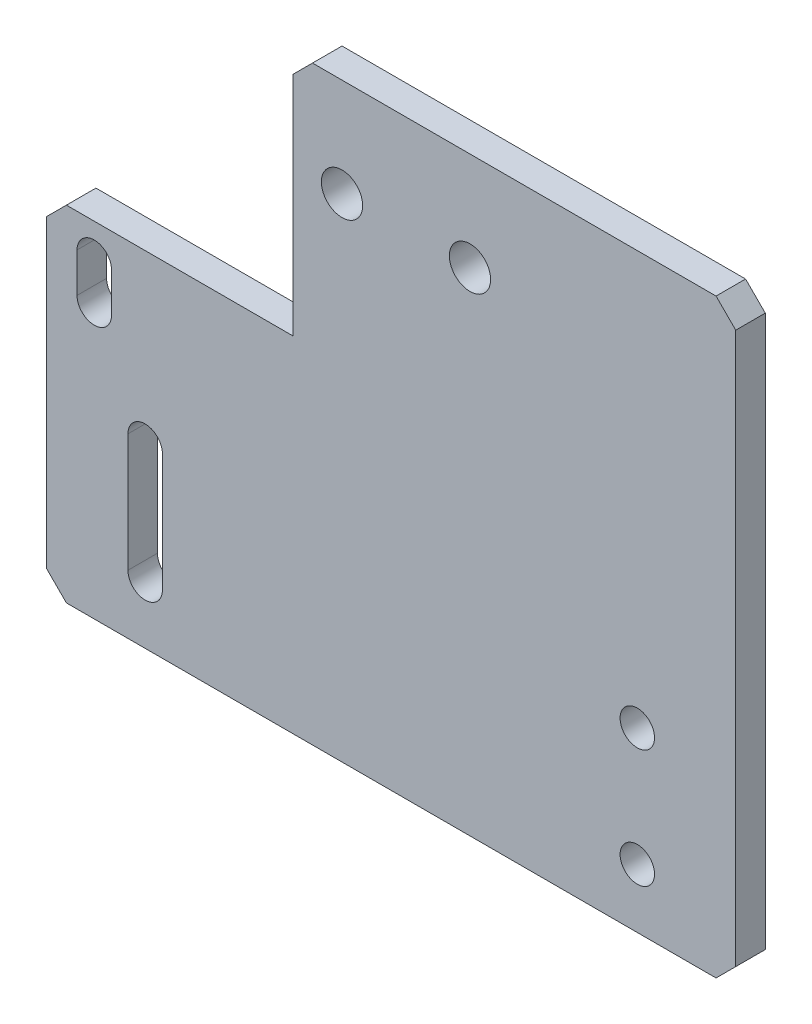
from build123d import *

# Parameters (mm, degrees)
SKETCH1_R           = 1.75
SKETCH1_R_2         = 2.096313729
BOSS_EXTRUDE1_DEPTH = 3
CHAMFER1_SIZE       = 2


with BuildPart() as part:
    # Sketch1 → Boss-Extrude1 (new body)
    with BuildSketch(Plane.XY):
        Polygon((-11.830357143, 26.84375), (33.169642857, 26.84375), (33.169642857, -33.15625), (-36.830357143, -33.15625), (-36.830357143, 1.84375), (-11.830357143, 1.84375), align=None)
        with Locations((23.169642857, -15.15625)):
            Circle(SKETCH1_R, mode=Mode.SUBTRACT)
        with Locations((23.169642857, -27.15625)):
            Circle(SKETCH1_R, mode=Mode.SUBTRACT)
        with Locations((6.169642857, 16.84375)):
            Circle(SKETCH1_R_2, mode=Mode.SUBTRACT)
        with Locations((-6.830357143, 16.84375)):
            Circle(SKETCH1_R_2, mode=Mode.SUBTRACT)
        with BuildLine():
            Line((-25.080357143, -15.15625), (-25.080357143, -27.15625))
            ThreePointArc((-25.080357143, -27.15625), (-26.830357143, -28.90625), (-28.580357143, -27.15625))
            Line((-28.580357143, -27.15625), (-28.580357143, -15.15625))
            ThreePointArc((-28.580357143, -15.15625), (-26.830357143, -13.40625), (-25.080357143, -15.15625))
        make_face(mode=Mode.SUBTRACT)
        with BuildLine():
            Line((-33.75, -1.558035714), (-33.75, -5.558035714))
            ThreePointArc((-33.75, -5.558035714), (-32, -7.308035714), (-30.25, -5.558035714))
            Line((-30.25, -5.558035714), (-30.25, -1.558035714))
            ThreePointArc((-30.25, -1.558035714), (-32, 0.191964286), (-33.75, -1.558035714))
        make_face(mode=Mode.SUBTRACT)
    extrude(amount=BOSS_EXTRUDE1_DEPTH)

    # Chamfer1
    chamfer1_edges = [part.edges().sort_by_distance(p)[0] for p in [
        (-11.830357143, 26.84375, 1.5),
        (33.169642857, 26.84375, 1.5),
        (33.169642857, -33.15625, 1.5),
        (-36.830357143, -33.15625, 1.5),
        (-36.830357143, 1.84375, 1.5),
    ]]
    chamfer(chamfer1_edges, length=CHAMFER1_SIZE)


solid = part.part
